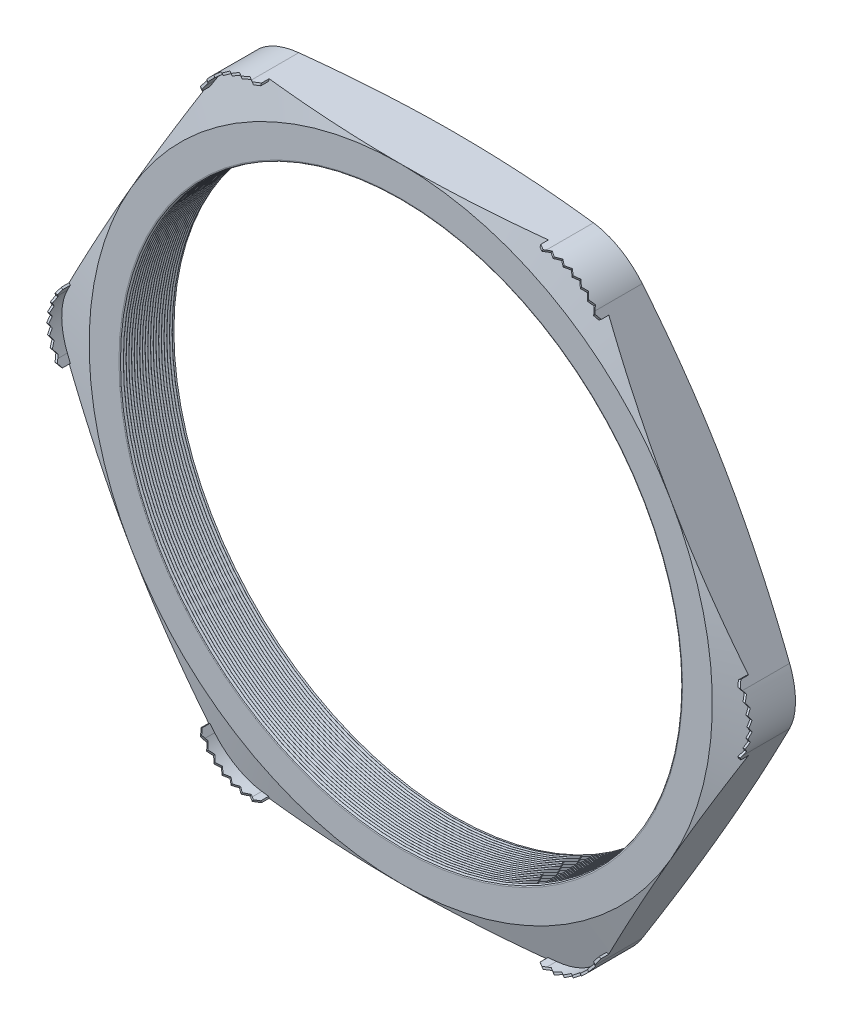
from build123d import *

# Parameters (mm, degrees)
SKETCH1_R          = 31.496
EXTRUDE1_DEPTH     = 6.096
FILLET1_R          = 6.35
FILLET3_R          = 0.2032
LPATTERN1_COUNT    = 20
LPATTERN1_PITCH    = 0.3048
SKETCH4_OUTSIDE_W  = 155.106
SKETCH4_OUTSIDE_H  = 146.226
SKETCH4_OUTSIDE_R  = 35.052
CUT_EXTRUDE1_DEPTH = 7.096
CUT_EXTRUDE1_DRAFT = -75
SKETCH5_OUTSIDE_W  = 155.106
SKETCH5_OUTSIDE_H  = 146.226
SKETCH5_OUTSIDE_R  = 35.052
CUT_EXTRUDE2_DEPTH = 7.0960001
CUT_EXTRUDE2_DRAFT = -75
EXTRUDE2_START     = -1.189752
EXTRUDE2_DEPTH     = 2.129552
CUT_EXTRUDE4_DEPTH = 13.090327257
CIRPATTERN1_COUNT  = 6
CIRPATTERN2_COUNT  = 6


with BuildPart() as part:
    # Sketch1 → Extrude1 (new body)
    with BuildSketch(Plane.XY):
        Polygon((-40.474563271, 0), (-20.237281636, -35.052), (20.237281636, -35.052), (40.474563271, 0), (20.237281636, 35.052), (-20.237281636, 35.052), align=None)
        Circle(SKETCH1_R, mode=Mode.SUBTRACT)
    extrude(amount=EXTRUDE1_DEPTH)

    # Fillet1
    fillet1_edges = [part.edges().sort_by_distance(p)[0] for p in [
        (40.474563271, 0, 3.048),
        (20.237281636, -35.052, 3.048),
        (-20.237281636, -35.052, 3.048),
        (-40.474563271, 0, 3.048),
        (-20.237281636, 35.052, 3.048),
        (20.237281636, 35.052, 3.048),
    ]]
    fillet(fillet1_edges, radius=FILLET1_R)

    # Fillet3
    fillet3_edges = [part.edges().sort_by_distance(p)[0] for p in [
        (-31.496, 0, 0),
        (-31.496, 0, 6.096),
    ]]
    fillet(fillet3_edges, radius=FILLET3_R)

    # Sketch3 → Cut-Revolve1 (revolve, cut)
    with BuildSketch(Plane(origin=(0, 0, 0), x_dir=(1, 0, 0), z_dir=(0, 1, 0))):
        Polygon((-31.496, -6.096), (-31.496, -5.802706063), (-31.75, -5.949353032), align=None)
    cut_revolve1 = revolve(axis=Axis((0, 0, 6.096), (0, 0, -1)), mode=Mode.SUBTRACT)

    # LPattern1: Cut-Revolve1 ×20
    with Locations(*[(0, 0, -i * LPATTERN1_PITCH) for i in range(1, LPATTERN1_COUNT)]):
        add(cut_revolve1, mode=Mode.SUBTRACT)


with BuildPart() as cut_extrude1_tool:
    # Sketch4 outside → Cut-Extrude1 (with draft: the straight prism first)
    with BuildSketch(Plane(origin=(0, 0, 0), x_dir=(-1, 0, 0), z_dir=(0, 0, -1))):
        Rectangle(SKETCH4_OUTSIDE_W, SKETCH4_OUTSIDE_H)
        Circle(SKETCH4_OUTSIDE_R, mode=Mode.SUBTRACT)
    extrude(amount=-CUT_EXTRUDE1_DEPTH)
    # Cut-Extrude1: the draft: its side faces are tilted about the plane it starts from
    cut_extrude1_sides = [cut_extrude1_tool.faces().sort_by_distance(p)[0] for p in [
        (0, -73.113, 3.548),
        (-77.553, 0, 3.548),
        (0, 73.113, 3.548),
        (77.553, 0, 3.548),
        (35.052, 0, 3.548),
    ]]
    draft(cut_extrude1_sides, Plane(origin=(0, 0, 0), x_dir=(-1, 0, 0), z_dir=(0, 0, -1)), CUT_EXTRUDE1_DRAFT)


with BuildPart() as part_1:
    add(part.part)

    # Cut-Extrude1: cut by cut_extrude1_tool
    add(cut_extrude1_tool.part, mode=Mode.SUBTRACT)


with BuildPart() as cut_extrude2_tool:
    # Sketch5 outside → Cut-Extrude2 (with draft: the straight prism first)
    with BuildSketch(Plane.XY.offset(6.096)):
        Rectangle(SKETCH5_OUTSIDE_W, SKETCH5_OUTSIDE_H)
        Circle(SKETCH5_OUTSIDE_R, mode=Mode.SUBTRACT)
    extrude(amount=-CUT_EXTRUDE2_DEPTH)
    # Cut-Extrude2: the draft: its side faces are tilted about the plane it starts from
    cut_extrude2_sides = [cut_extrude2_tool.faces().sort_by_distance(p)[0] for p in [
        (0, -73.113, 2.54799995),
        (77.553, 0, 2.54799995),
        (0, 73.113, 2.54799995),
        (-77.553, 0, 2.54799995),
        (-35.052, 0, 2.54799995),
    ]]
    draft(cut_extrude2_sides, Plane.XY.offset(6.096), CUT_EXTRUDE2_DRAFT)


with BuildPart() as part_2:
    add(part_1.part)

    # Cut-Extrude2: cut by cut_extrude2_tool
    add(cut_extrude2_tool.part, mode=Mode.SUBTRACT)

    # Sketch2 → Extrude2 (add)
    with BuildSketch(Plane.XY.offset(6.096).offset(EXTRUDE2_START)):
        with BuildLine():
            Line((-16.571107426, 35.052), (-15.707507426, 35.052))
            Line((-15.707507426, 35.052), (-15.707507426, 34.8234))
            Line((-15.707507426, 34.8234), (-16.571107426, 34.8234))
            ThreePointArc((-16.571107426, 34.8234), (-19.631807426, 34.003287907), (-21.872395333, 31.7627))
            Line((-21.872395333, 31.7627), (-22.304195333, 31.014800461))
            Line((-22.304195333, 31.014800461), (-22.50216874, 31.129100461))
            Line((-22.50216874, 31.129100461), (-22.07036874, 31.877))
            ThreePointArc((-22.07036874, 31.877), (-19.746107426, 34.201261314), (-16.571107426, 35.052))
        make_face()
    extrude2 = extrude(amount=EXTRUDE2_DEPTH)

    # Sketch7 → Cut-Extrude4 (cut, through all)
    with BuildSketch(Plane(origin=(-19.00585138, 32.919100231, 0), x_dir=(0.866025404, 0.5, 0), z_dir=(0.5, -0.866025404, 0))):
        Polygon((-3.922899539, 6.04901), (-3.364099539, 6.443726), (-2.805299539, 6.04901), (-2.2352, 6.443726), (-1.6764, 6.04901), (-1.1176, 6.443726), (-0.5588, 6.04901), (0, 6.443726), (0.5588, 6.04901), (1.1176, 6.443726), (1.6764, 6.04901), (2.2352, 6.443726), (2.794, 6.04901), (3.364099539, 6.443726), (3.922899539, 6.04901), (3.922899539, 7.0358), (-3.922899539, 7.0358), align=None)
    cut_extrude4 = extrude(amount=-CUT_EXTRUDE4_DEPTH, mode=Mode.SUBTRACT)

    # CirPattern1: Extrude2 ×6 about axis
    cirpattern1_axis = Axis((0, 0, 0), (0, 0, 1))
    for i in range(1, CIRPATTERN1_COUNT):
        add(extrude2.rotate(cirpattern1_axis, i * 360 / CIRPATTERN1_COUNT))

    # CirPattern2: Cut-Extrude4 ×6 about axis
    cirpattern2_axis = Axis((0, 0, 0), (0, 0, 1))
    for i in range(1, CIRPATTERN2_COUNT):
        add(cut_extrude4.rotate(cirpattern2_axis, i * 360 / CIRPATTERN2_COUNT), mode=Mode.SUBTRACT)


solid = part_2.part
